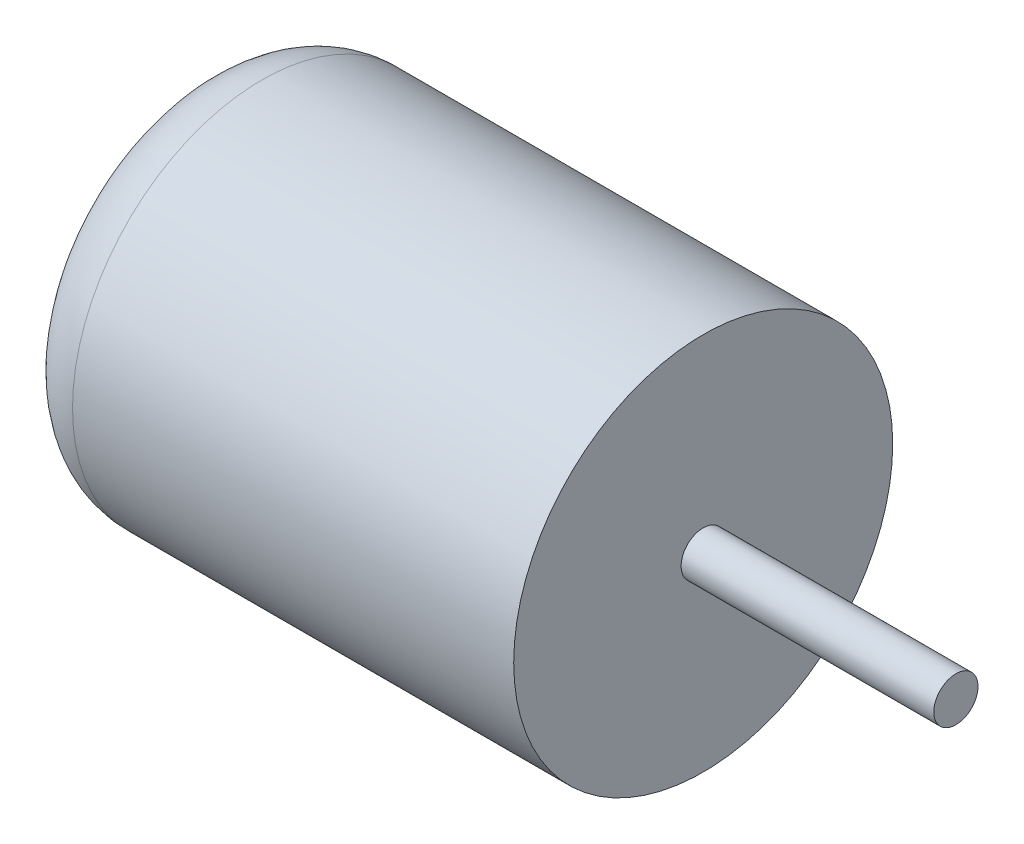
from build123d import *

# Parameters (mm, degrees)
SKETCH1_R           = 7.5
BOSS_EXTRUDE1_DEPTH = 20
SKETCH2_R           = 0.875
BOSS_EXTRUDE2_DEPTH = 10
FILLET1_R           = 2.54


with BuildPart() as part:
    # Sketch1 → Boss-Extrude1 (new body)
    with BuildSketch(Plane(origin=(0, 0, 0), x_dir=(0, 0, -1), z_dir=(1, 0, 0))):
        Circle(SKETCH1_R)
    extrude(amount=BOSS_EXTRUDE1_DEPTH)

    # Sketch2 → Boss-Extrude2 (add)
    with BuildSketch(Plane(origin=(20, 0, 0), x_dir=(0, 0, -1), z_dir=(1, 0, 0))):
        Circle(SKETCH2_R)
    extrude(amount=BOSS_EXTRUDE2_DEPTH)

    # Fillet1
    fillet1_edges = [part.edges().sort_by_distance(p)[0] for p in [
        (0, 0, 7.5),
    ]]
    fillet(fillet1_edges, radius=FILLET1_R)


solid = part.part
